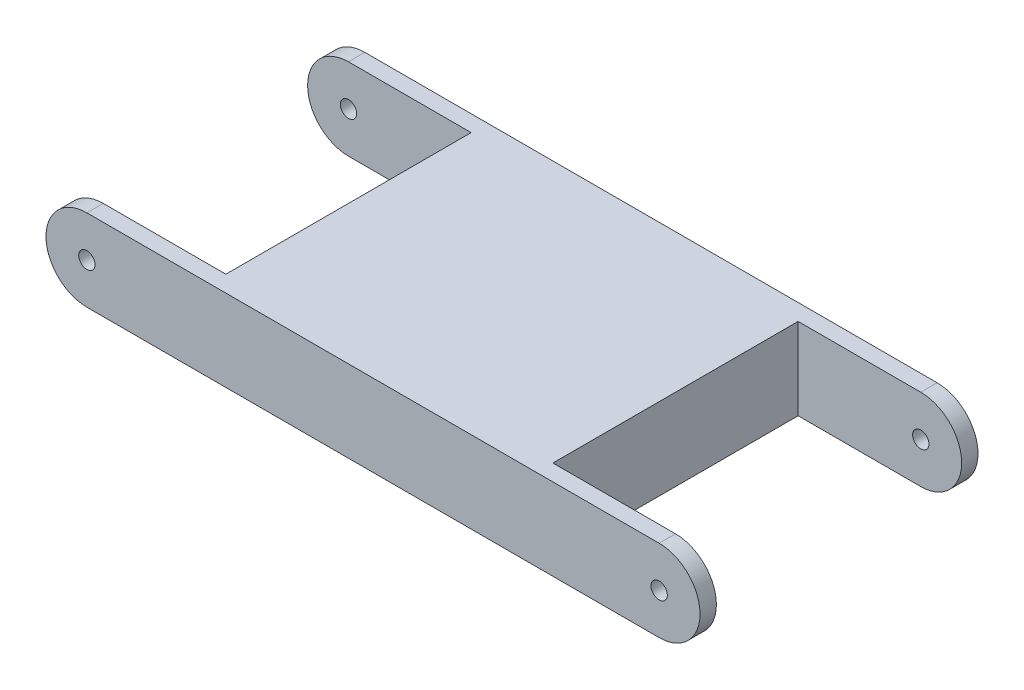
from build123d import *

# Parameters (mm, degrees)
EXTRUDE_1_DEPTH          = 34
SKETCH_2_R               = 1
CUT_EXTRUDE_4_DEPTH      = 35
CUT_EXTRUDE_4_DEPTH_BACK = 30
SKETCH_3_W               = 20
SKETCH_3_H               = 30
CUT_EXTRUDE_5_DEPTH      = 30
CUT_EXTRUDE_5_DEPTH_BACK = 30


with BuildPart() as part:
    # 草圖1 → 填料-伸長1 (new body)
    with BuildSketch(Plane.XY):
        with BuildLine():
            Line((-35, 5), (35, 5))
            ThreePointArc((35, 5), (40, 0), (35, -5))
            Line((35, -5), (-35, -5))
            ThreePointArc((-35, -5), (-40, 0), (-35, 5))
        make_face()
    extrude(amount=EXTRUDE_1_DEPTH)

    # 草圖2 → 除料-伸長4 (cut, two sides)
    with BuildSketch(Plane.XY) as cut_extrude_4_sk:
        with Locations((-35, 0)):
            Circle(SKETCH_2_R)
        with Locations((35, 0)):
            Circle(SKETCH_2_R)
    extrude(amount=CUT_EXTRUDE_4_DEPTH, mode=Mode.SUBTRACT)
    extrude(cut_extrude_4_sk.sketch, amount=-CUT_EXTRUDE_4_DEPTH_BACK, mode=Mode.SUBTRACT)

    # 草圖3 → 除料-伸長5 (cut, two sides)
    with BuildSketch(Plane(origin=(0, 0, 0), x_dir=(1, 0, 0), z_dir=(0, 1, 0))) as cut_extrude_5_sk:
        with Locations((-30, -17)):
            Rectangle(SKETCH_3_W, SKETCH_3_H)
        with Locations((30, -17)):
            Rectangle(SKETCH_3_W, SKETCH_3_H)
    extrude(amount=CUT_EXTRUDE_5_DEPTH, mode=Mode.SUBTRACT)
    extrude(cut_extrude_5_sk.sketch, amount=-CUT_EXTRUDE_5_DEPTH_BACK, mode=Mode.SUBTRACT)


solid = part.part
